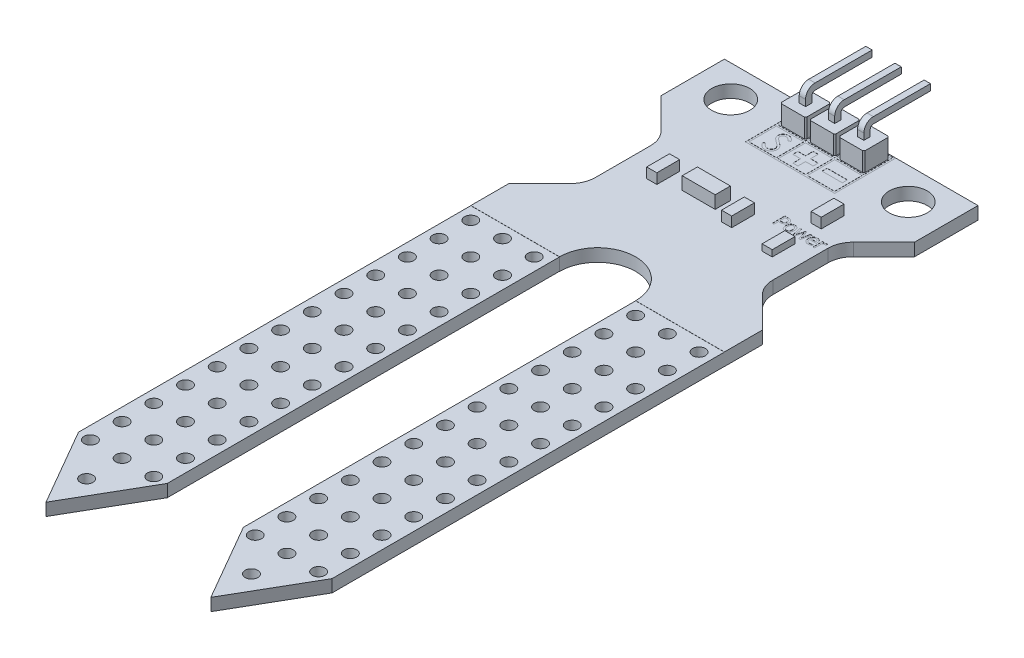
from build123d import *

# Parameters (mm, degrees)
BASE_DEPTH           = 0.5
HOLES_REACH          = 3
SKETCH2_R            = 1.5
PLATE_DEPTH          = 0.49
SKETCH4_R            = 0.5
PLATE_HOLES_DEPTH    = 1.99
SOCKET_DEPTH         = 1.5
POWER_PIN_DEPTH      = 0.25
LPATTERN2_COUNT      = 2
LPATTERN2_PITCH      = 2.3
LPATTERN2_COL_COUNT  = 2
LPATTERN2_COL_PITCH  = 2.3
SKETCH9_W            = 7.04
SKETCH9_H            = 4.74
SKETCH9_W_2          = 2.16
SKETCH9_H_2          = 2.16
SKETCH9_W_3          = 1.6
SKETCH9_H_3          = 0.4
CUT_EXTRUDE3_DEPTH   = 0.01
SKETCH10_W           = 2.6
SKETCH10_H           = 1.2
BIG_RESISTOR_DEPTH   = 1
SKETCH11_W           = 0.8
SKETCH11_H           = 1.8
SMALL_RESISTOR_DEPTH = 0.8
SKETCH12_W           = 0.8
SKETCH12_H           = 1.8
LIGHT_DEPTH          = 0.5


with BuildPart() as part:
    # Sketch1 → Base (new body, symmetric)
    with BuildSketch(Plane(origin=(0, 0, 0), x_dir=(1, 0, 0), z_dir=(0, 1, 0))):
        with BuildLine():
            Line((-10, 0), (10, 0))
            Line((10, 0), (10, -5))
            Line((10, -5), (7.585786438, -7.414213562))
            ThreePointArc((7.585786438, -7.414213562), (7.152240935, -8.06306026), (7, -8.828427125))
            Line((7, -8.828427125), (7, -13.171572875))
            ThreePointArc((7, -13.171572875), (7.152240935, -13.93693974), (7.585786438, -14.585786438))
            Line((7.585786438, -14.585786438), (10, -17))
            Line((10, -17), (10, -20))
            Line((10, -20), (3, -20))
            ThreePointArc((3, -20), (0, -17), (-3, -20))
            Line((-3, -20), (-10, -20))
            Line((-10, -20), (-10, -17))
            Line((-10, -17), (-7.585786438, -14.585786438))
            ThreePointArc((-7.585786438, -14.585786438), (-7.152240935, -13.93693974), (-7, -13.171572875))
            Line((-7, -13.171572875), (-7, -8.828427125))
            ThreePointArc((-7, -8.828427125), (-7.152240935, -8.06306026), (-7.585786438, -7.414213562))
            Line((-7.585786438, -7.414213562), (-10, -5))
            Line((-10, -5), (-10, 0))
        make_face()
    extrude(amount=BASE_DEPTH, both=True)

    # Sketch2 → Holes (cut, up to next)
    with BuildSketch(Plane(origin=(0, 0.5, 0), x_dir=(1, 0, 0), z_dir=(0, 1, 0)), mode=Mode.PRIVATE) as holes_sk1:
        with Locations((-7, -2.5)):
            Circle(SKETCH2_R)
    holes_tool1 = extrude(holes_sk1.sketch, amount=-HOLES_REACH, mode=Mode.PRIVATE) & part.part
    add(holes_tool1.solids().sort_by_distance((-7, 0.5, 2.5))[0], mode=Mode.SUBTRACT)
    # Sketch2 → Holes (cut, up to next)
    with BuildSketch(Plane(origin=(0, 0.5, 0), x_dir=(1, 0, 0), z_dir=(0, 1, 0)), mode=Mode.PRIVATE) as holes_sk2:
        with Locations((7, -2.5)):
            Circle(SKETCH2_R)
    holes_tool2 = extrude(holes_sk2.sketch, amount=-HOLES_REACH, mode=Mode.PRIVATE) & part.part
    add(holes_tool2.solids().sort_by_distance((7, 0.5, 2.5))[0], mode=Mode.SUBTRACT)

    # Sketch3 → Plate (add, symmetric)
    with BuildSketch(Plane(origin=(0, 0, 0), x_dir=(1, 0, 0), z_dir=(0, 1, 0))):
        Polygon((-10, -20), (-3, -20), (-3, -50.937822174), (-6.5, -57), (-10, -50.937822174), align=None)
        Polygon((3, -50.937822174), (3, -20), (10, -20), (10, -50.937822174), (6.5, -57), align=None)
    extrude(amount=PLATE_DEPTH, both=True)

    # Sketch4 → Plate holes (cut, through all)
    with BuildSketch(Plane(origin=(0, 0.49, 0), x_dir=(1, 0, 0), z_dir=(0, 1, 0))):
        with Locations((-9, -21)):
            Circle(SKETCH4_R)
        with Locations((-6.5, -21)):
            Circle(SKETCH4_R)
        with Locations((-4, -21)):
            Circle(SKETCH4_R)
        with Locations((-6.5, -23.5)):
            Circle(SKETCH4_R)
        with Locations((-4, -23.5)):
            Circle(SKETCH4_R)
        with Locations((-6.5, -26)):
            Circle(SKETCH4_R)
        with Locations((-4, -26)):
            Circle(SKETCH4_R)
        with Locations((-6.5, -28.5)):
            Circle(SKETCH4_R)
        with Locations((-4, -28.5)):
            Circle(SKETCH4_R)
        with Locations((-6.5, -31)):
            Circle(SKETCH4_R)
        with Locations((-4, -31)):
            Circle(SKETCH4_R)
        with Locations((-6.5, -33.5)):
            Circle(SKETCH4_R)
        with Locations((-4, -33.5)):
            Circle(SKETCH4_R)
        with Locations((-6.5, -36)):
            Circle(SKETCH4_R)
        with Locations((-4, -36)):
            Circle(SKETCH4_R)
        with Locations((-6.5, -38.5)):
            Circle(SKETCH4_R)
        with Locations((-4, -38.5)):
            Circle(SKETCH4_R)
        with Locations((-6.5, -41)):
            Circle(SKETCH4_R)
        with Locations((-4, -41)):
            Circle(SKETCH4_R)
        with Locations((-6.5, -43.5)):
            Circle(SKETCH4_R)
        with Locations((-4, -43.5)):
            Circle(SKETCH4_R)
        with Locations((-6.5, -46)):
            Circle(SKETCH4_R)
        with Locations((-4, -46)):
            Circle(SKETCH4_R)
        with Locations((-6.5, -48.5)):
            Circle(SKETCH4_R)
        with Locations((-4, -48.5)):
            Circle(SKETCH4_R)
        with Locations((-6.5, -51)):
            Circle(SKETCH4_R)
        with Locations((-4, -51)):
            Circle(SKETCH4_R)
        with Locations((-9, -23.5)):
            Circle(SKETCH4_R)
        with Locations((-9, -26)):
            Circle(SKETCH4_R)
        with Locations((-9, -28.5)):
            Circle(SKETCH4_R)
        with Locations((-9, -31)):
            Circle(SKETCH4_R)
        with Locations((-9, -33.5)):
            Circle(SKETCH4_R)
        with Locations((-9, -36)):
            Circle(SKETCH4_R)
        with Locations((-9, -38.5)):
            Circle(SKETCH4_R)
        with Locations((-9, -41)):
            Circle(SKETCH4_R)
        with Locations((-9, -43.5)):
            Circle(SKETCH4_R)
        with Locations((-9, -46)):
            Circle(SKETCH4_R)
        with Locations((-9, -48.5)):
            Circle(SKETCH4_R)
        with Locations((-9, -51)):
            Circle(SKETCH4_R)
        with Locations((-6.5, -53.8)):
            Circle(SKETCH4_R)
        with Locations((6.5, -53.8)):
            Circle(SKETCH4_R)
        with Locations((9, -51)):
            Circle(SKETCH4_R)
        with Locations((9, -48.5)):
            Circle(SKETCH4_R)
        with Locations((9, -46)):
            Circle(SKETCH4_R)
        with Locations((9, -43.5)):
            Circle(SKETCH4_R)
        with Locations((9, -41)):
            Circle(SKETCH4_R)
        with Locations((9, -38.5)):
            Circle(SKETCH4_R)
        with Locations((9, -36)):
            Circle(SKETCH4_R)
        with Locations((9, -33.5)):
            Circle(SKETCH4_R)
        with Locations((9, -31)):
            Circle(SKETCH4_R)
        with Locations((9, -28.5)):
            Circle(SKETCH4_R)
        with Locations((9, -26)):
            Circle(SKETCH4_R)
        with Locations((9, -23.5)):
            Circle(SKETCH4_R)
        with Locations((4, -51)):
            Circle(SKETCH4_R)
        with Locations((6.5, -51)):
            Circle(SKETCH4_R)
        with Locations((4, -48.5)):
            Circle(SKETCH4_R)
        with Locations((6.5, -48.5)):
            Circle(SKETCH4_R)
        with Locations((4, -46)):
            Circle(SKETCH4_R)
        with Locations((6.5, -46)):
            Circle(SKETCH4_R)
        with Locations((4, -43.5)):
            Circle(SKETCH4_R)
        with Locations((6.5, -43.5)):
            Circle(SKETCH4_R)
        with Locations((4, -41)):
            Circle(SKETCH4_R)
        with Locations((6.5, -41)):
            Circle(SKETCH4_R)
        with Locations((4, -38.5)):
            Circle(SKETCH4_R)
        with Locations((6.5, -38.5)):
            Circle(SKETCH4_R)
        with Locations((4, -36)):
            Circle(SKETCH4_R)
        with Locations((6.5, -36)):
            Circle(SKETCH4_R)
        with Locations((4, -33.5)):
            Circle(SKETCH4_R)
        with Locations((6.5, -33.5)):
            Circle(SKETCH4_R)
        with Locations((4, -31)):
            Circle(SKETCH4_R)
        with Locations((6.5, -31)):
            Circle(SKETCH4_R)
        with Locations((4, -28.5)):
            Circle(SKETCH4_R)
        with Locations((6.5, -28.5)):
            Circle(SKETCH4_R)
        with Locations((4, -26)):
            Circle(SKETCH4_R)
        with Locations((6.5, -26)):
            Circle(SKETCH4_R)
        with Locations((4, -23.5)):
            Circle(SKETCH4_R)
        with Locations((6.5, -23.5)):
            Circle(SKETCH4_R)
        with Locations((4, -21)):
            Circle(SKETCH4_R)
        with Locations((6.5, -21)):
            Circle(SKETCH4_R)
        with Locations((9, -21)):
            Circle(SKETCH4_R)
    extrude(amount=-PLATE_HOLES_DEPTH, mode=Mode.SUBTRACT)

    # Sketch5 → Socket (add)
    with BuildSketch(Plane(origin=(0, 0.5, 0), x_dir=(1, 0, 0), z_dir=(0, 1, 0))):
        Polygon((-3.2, -0.3), (-3.3, -0.4), (-3.3, -2.2), (-3.2, -2.3), (-1.4, -2.3), (-1.3, -2.2), (-1.3, -0.4), (-1.4, -0.3), align=None)
        Polygon((-0.9, -0.3), (-1, -0.4), (-1, -2.2), (-0.9, -2.3), (0.9, -2.3), (1, -2.2), (1, -0.4), (0.9, -0.3), align=None)
        Polygon((1.4, -0.3), (1.3, -0.4), (1.3, -2.2), (1.4, -2.3), (3.2, -2.3), (3.3, -2.2), (3.3, -0.4), (3.2, -0.3), align=None)
    extrude(amount=SOCKET_DEPTH)

    # Sketch7 → Power pin (add, symmetric)
    with BuildSketch(Plane(origin=(0, 0, 0), x_dir=(0, 0, -1), z_dir=(1, 0, 0))):
        with BuildLine():
            Line((-1.05, 2), (-1.05, 2.5))
            ThreePointArc((-1.05, 2.5), (-0.976776695, 2.676776695), (-0.8, 2.75))
            Line((-0.8, 2.75), (3.7, 2.75))
            Line((3.7, 2.75), (3.7, 3.25))
            Line((3.7, 3.25), (-0.8, 3.25))
            ThreePointArc((-0.8, 3.25), (-1.330330086, 3.030330086), (-1.55, 2.5))
            Line((-1.55, 2.5), (-1.55, 2))
            Line((-1.55, 2), (-1.05, 2))
        make_face()
    power_pin = extrude(amount=POWER_PIN_DEPTH, both=True)

    # LPattern2: Power pin ×2
    with Locations(*[(i * LPATTERN2_PITCH, 0, 0) for i in range(1, LPATTERN2_COUNT)]):
        add(power_pin)

    # LPattern2 col: Power pin ×2
    with Locations(*[(-i * LPATTERN2_COL_PITCH, 0, 0) for i in range(1, LPATTERN2_COL_COUNT)]):
        add(power_pin)

    # Sketch9 → Cut-Extrude3 (cut)
    with BuildSketch(Plane(origin=(0, 0.5, 0), x_dir=(1, 0, 0), z_dir=(0, 1, 0))):
        with Locations((0, -2.45)):
            Rectangle(SKETCH9_W, SKETCH9_H)
        with Locations((-2.3, -3.6)):
            Rectangle(SKETCH9_W_2, SKETCH9_H_2, mode=Mode.SUBTRACT)
        with Locations((2.3, -3.6)):
            Rectangle(SKETCH9_W_2, SKETCH9_H_2, mode=Mode.SUBTRACT)
        with Locations((0, -3.6)):
            Rectangle(SKETCH9_W_2, SKETCH9_H_2, mode=Mode.SUBTRACT)
        with Locations((2.3, -1.3)):
            Rectangle(SKETCH9_W_2, SKETCH9_H_2, mode=Mode.SUBTRACT)
        with Locations((0, -1.3)):
            Rectangle(SKETCH9_W_2, SKETCH9_H_2, mode=Mode.SUBTRACT)
        with Locations((-2.3, -1.3)):
            Rectangle(SKETCH9_W_2, SKETCH9_H_2, mode=Mode.SUBTRACT)
        Polygon((0.2, -3.8), (0.2, -4.4), (-0.2, -4.4), (-0.2, -3.8), (-0.8, -3.8), (-0.8, -3.4), (-0.2, -3.4), (-0.2, -2.8), (0.2, -2.8), (0.2, -3.4), (0.8, -3.4), (0.8, -3.8), align=None)
        with Locations((2.3, -3.6)):
            Rectangle(SKETCH9_W_3, SKETCH9_H_3)
        with BuildLine():
            add(Edge.make_bspline(
                [(-2.246490385, -4.576153846), (-2.273532617, -4.576315645), (-2.313654059, -4.573047968), (-2.366227141, -4.564203593), (-2.404086372, -4.553842087), (-2.441134062, -4.54125028), (-2.477209816, -4.525751551), (-2.512330919, -4.507176722), (-2.546694255, -4.485939358), (-2.58021238, -4.461223914), (-2.612571051, -4.432437596), (-2.644831422, -4.400374008), (-2.676043505, -4.364163602), (-2.706829687, -4.324386751), (-2.747659195, -4.264495287), (-2.775757513, -4.216295891), (-2.793846154, -4.182764423)],
                knots=[0, 0, 0, 0, 0.11369606, 0.169177916, 0.224159217, 0.278719878, 0.333794217, 0.389241459, 0.445822073, 0.503704281, 0.564293892, 0.627975416, 0.69503826, 0.765372726, 0.839611443, 1, 1, 1, 1], degree=3))
            Line((-2.793846154, -4.182764423), (-2.641682692, -4.091538462))
            add(Edge.make_bspline(
                [(-2.641682692, -4.091538462), (-2.615333113, -4.137281357), (-2.573720129, -4.20142962), (-2.508305323, -4.274072684), (-2.459465517, -4.316713706), (-2.408925617, -4.350224043), (-2.339499767, -4.381822359), (-2.283518044, -4.391635907), (-2.246490385, -4.391538462)],
                knots=[0, 0, 0, 0, 0.3046461, 0.438546905, 0.562322299, 0.677432543, 0.786897393, 1, 1, 1, 1], degree=3))
            add(Edge.make_bspline(
                [(-2.246490385, -4.391538462), (-2.215186191, -4.391820786), (-2.168541844, -4.386320718), (-2.108627287, -4.368972193), (-2.066142471, -4.350573946), (-2.026493488, -4.32827934), (-1.991723956, -4.301359985), (-1.961667208, -4.271219408), (-1.937075124, -4.237593574), (-1.918227568, -4.20143252), (-1.898856875, -4.152032077), (-1.894321716, -4.112425622), (-1.893846154, -4.086490385)],
                knots=[0, 0, 0, 0, 0.180930311, 0.27008822, 0.360156133, 0.448342532, 0.532665842, 0.613833704, 0.693981527, 0.772715977, 0.849335172, 1, 1, 1, 1], degree=3))
            add(Edge.make_bspline(
                [(-1.893846154, -4.086490385), (-1.893676765, -4.055991813), (-1.905960341, -3.99236022), (-1.938768022, -3.936635259), (-1.958389423, -3.909807692)],
                knots=[0, 0, 0, 0, 0.477158319, 1, 1, 1, 1], degree=3))
            add(Edge.make_bspline(
                [(-1.958389423, -3.909807692), (-1.974979405, -3.887924698), (-2.003044983, -3.854740657), (-2.046593296, -3.812409427), (-2.084590972, -3.776886112), (-2.127862178, -3.740740402), (-2.193103704, -3.687488516), (-2.246255026, -3.649200638), (-2.282908654, -3.622788462)],
                knots=[0, 0, 0, 0, 0.189529918, 0.299197872, 0.418925887, 0.548376285, 0.68813637, 1, 1, 1, 1], degree=3))
            add(Edge.make_bspline(
                [(-2.282908654, -3.622788462), (-2.319332486, -3.597298459), (-2.370311348, -3.559474956), (-2.433967391, -3.510236121), (-2.473696699, -3.478200971), (-2.507834061, -3.449097245), (-2.543316445, -3.417339903), (-2.565438588, -3.393305532), (-2.577860577, -3.377956731)],
                knots=[0, 0, 0, 0, 0.347081672, 0.495567816, 0.628357302, 0.74551967, 0.845830751, 1, 1, 1, 1], degree=3))
            add(Edge.make_bspline(
                [(-2.577860577, -3.377956731), (-2.593776531, -3.357350823), (-2.615964811, -3.325716744), (-2.639676206, -3.280617496), (-2.653448515, -3.246424078), (-2.665023886, -3.21184492), (-2.675502407, -3.164553806), (-2.678598853, -3.128201284), (-2.678461538, -3.103918269)],
                knots=[0, 0, 0, 0, 0.262558979, 0.388264447, 0.512667355, 0.63372227, 0.75539386, 1, 1, 1, 1], degree=3))
            add(Edge.make_bspline(
                [(-2.678461538, -3.103918269), (-2.678553734, -3.066252593), (-2.671447507, -3.010220346), (-2.647478206, -2.939595989), (-2.62266971, -2.890054956), (-2.590643888, -2.84481532), (-2.55359371, -2.803356628), (-2.509461666, -2.768505533), (-2.461039929, -2.738048494), (-2.408041541, -2.714232988), (-2.333433939, -2.689984634), (-2.274246585, -2.68435437), (-2.234951923, -2.683846154)],
                knots=[0, 0, 0, 0, 0.165779888, 0.246280008, 0.327460928, 0.408796954, 0.489715241, 0.571376032, 0.655523321, 0.741019483, 0.826546761, 1, 1, 1, 1], degree=3))
            add(Edge.make_bspline(
                [(-2.234951923, -2.683846154), (-2.192822847, -2.683778289), (-2.129561237, -2.691525523), (-2.049769386, -2.719640703), (-2.001713874, -2.743365307), (-1.964102617, -2.767094216), (-1.935419451, -2.788703433), (-1.906353652, -2.813582569), (-1.876668732, -2.841794847), (-1.846876235, -2.873605751), (-1.805150747, -2.921908707), (-1.774984467, -2.960923517), (-1.755384615, -2.988533654)],
                knots=[0, 0, 0, 0, 0.213251813, 0.318830447, 0.426793531, 0.483645951, 0.543603822, 0.60830765, 0.67712676, 0.750685636, 0.828713418, 1, 1, 1, 1], degree=3))
            Line((-1.755384615, -2.988533654), (-1.901418269, -3.099230769))
            add(Edge.make_bspline(
                [(-1.901418269, -3.099230769), (-1.918152053, -3.077154577), (-1.943547889, -3.046203482), (-1.977300729, -3.007374607), (-2.001237063, -2.983063683), (-2.023554691, -2.961103375), (-2.045214679, -2.942300853), (-2.065906655, -2.92647406), (-2.091989734, -2.909580502), (-2.124758085, -2.892855124), (-2.179943857, -2.873750803), (-2.223743197, -2.868638568), (-2.252980769, -2.868461538)],
                knots=[0, 0, 0, 0, 0.189629101, 0.274184089, 0.352183161, 0.423198873, 0.488550946, 0.548473346, 0.601440164, 0.701198082, 0.799591802, 1, 1, 1, 1], degree=3))
            add(Edge.make_bspline(
                [(-2.252980769, -2.868461538), (-2.288760118, -2.86794829), (-2.341326045, -2.875600288), (-2.404161728, -2.904100386), (-2.443540668, -2.93303211), (-2.476282849, -2.967351191), (-2.508192012, -3.020207311), (-2.51686998, -3.066044557), (-2.516923077, -3.096346154)],
                knots=[0, 0, 0, 0, 0.275902964, 0.402370856, 0.528413645, 0.650356379, 0.765895086, 1, 1, 1, 1], degree=3))
            add(Edge.make_bspline(
                [(-2.516923077, -3.096346154), (-2.517539684, -3.115722128), (-2.513143133, -3.144479643), (-2.503403158, -3.182255061), (-2.491936029, -3.210503374), (-2.476063781, -3.239039588), (-2.446620415, -3.280532441), (-2.418546908, -3.309399632), (-2.398293269, -3.328918269)],
                knots=[0, 0, 0, 0, 0.214745861, 0.32293856, 0.434116163, 0.553412311, 0.686072985, 1, 1, 1, 1], degree=3))
            add(Edge.make_bspline(
                [(-2.398293269, -3.328918269), (-2.389042289, -3.337396199), (-2.372125001, -3.35132235), (-2.345275359, -3.371329108), (-2.31778666, -3.392209601), (-2.284886018, -3.416419074), (-2.230365405, -3.455214082), (-2.187146804, -3.486462007), (-2.156346154, -3.508125)],
                knots=[0, 0, 0, 0, 0.124951974, 0.218093899, 0.333502411, 0.468789179, 0.624937586, 1, 1, 1, 1], degree=3))
            add(Edge.make_bspline(
                [(-2.156346154, -3.508125), (-2.118469517, -3.535564261), (-2.063761069, -3.575795807), (-1.996356754, -3.63167221), (-1.952403412, -3.670950709), (-1.912867071, -3.708765499), (-1.878184215, -3.745569323), (-1.848004854, -3.781099122), (-1.815504812, -3.826650485), (-1.782356478, -3.882596668), (-1.744802823, -3.972233355), (-1.732343451, -4.042695168), (-1.732307692, -4.089014423)],
                knots=[0, 0, 0, 0, 0.187773439, 0.272396139, 0.351320997, 0.424334774, 0.491908784, 0.55423322, 0.611267658, 0.716347845, 0.814540086, 1, 1, 1, 1], degree=3))
            add(Edge.make_bspline(
                [(-1.732307692, -4.089014423), (-1.73180834, -4.121010342), (-1.737031862, -4.168370829), (-1.752300775, -4.229625604), (-1.76926769, -4.273294873), (-1.790011741, -4.315849132), (-1.816324044, -4.356173249), (-1.84682563, -4.395159376), (-1.881814286, -4.431768058), (-1.920100785, -4.46537458), (-1.960566684, -4.495269858), (-2.003278223, -4.520195214), (-2.048003875, -4.540540115), (-2.094753202, -4.556431906), (-2.160627295, -4.572091465), (-2.211953075, -4.576287109), (-2.246490385, -4.576153846)],
                knots=[0, 0, 0, 0, 0.121774528, 0.18091956, 0.240256115, 0.300114444, 0.361145948, 0.423500582, 0.488669361, 0.553954105, 0.617581261, 0.680238427, 0.742187389, 0.804663212, 0.868258989, 1, 1, 1, 1], degree=3))
        make_face()
        with BuildLine():
            add(Edge.make_bspline(
                [(3.614912975, -8.391520479), (3.633163899, -8.404040768), (3.658411823, -8.425948178), (3.685654097, -8.46087403), (3.703330738, -8.48928983), (3.717341928, -8.520703016), (3.730875146, -8.568320938), (3.734174902, -8.606496516), (3.734177215, -8.632620163)],
                knots=[0, 0, 0, 0, 0.236652735, 0.354095324, 0.472428991, 0.593574989, 0.720487505, 1, 1, 1, 1], degree=3))
            add(Edge.make_bspline(
                [(3.734177215, -8.632620163), (3.734440026, -8.65413018), (3.73119797, -8.686086104), (3.721473566, -8.727478688), (3.711089093, -8.757085204), (3.698453563, -8.785275409), (3.678015797, -8.819787273), (3.659487713, -8.843157966), (3.645371835, -8.856908137)],
                knots=[0, 0, 0, 0, 0.260381683, 0.387741643, 0.51462425, 0.640165698, 0.76161061, 1, 1, 1, 1], degree=3))
            add(Edge.make_bspline(
                [(3.645371835, -8.856908137), (3.628222596, -8.874168407), (3.59926142, -8.896823181), (3.556438332, -8.920876751), (3.521585919, -8.935975104), (3.483093971, -8.94749291), (3.423362636, -8.958938368), (3.375658725, -8.96133288), (3.342563291, -8.961338517)],
                knots=[0, 0, 0, 0, 0.221351823, 0.332954221, 0.446758858, 0.566651796, 0.698228055, 1, 1, 1, 1], degree=3))
            Line((3.342563291, -8.961338517), (3.227848101, -8.961338517))
            Line((3.227848101, -8.961338517), (3.227848101, -9.328427125))
            Line((3.227848101, -9.328427125), (3.101265823, -9.328427125))
            Line((3.101265823, -9.328427125), (3.101265823, -8.328427125))
            Line((3.101265823, -8.328427125), (3.353045886, -8.328427125))
            add(Edge.make_bspline(
                [(3.353045886, -8.328427125), (3.380558098, -8.328591969), (3.420312752, -8.329842529), (3.470780842, -8.336395884), (3.504037276, -8.342925648), (3.534802149, -8.351368673), (3.572563912, -8.365779841), (3.598766283, -8.380299011), (3.614912975, -8.391520479)],
                knots=[0, 0, 0, 0, 0.30181566, 0.435226341, 0.557564183, 0.673137959, 0.784559398, 1, 1, 1, 1], degree=3))
        make_face()
        with BuildLine():
            add(Edge.make_bspline(
                [(3.537381329, -8.786892315), (3.547149877, -8.777187217), (3.559916605, -8.76124491), (3.573428862, -8.738111904), (3.581476261, -8.720221024), (3.587667462, -8.701198951), (3.59357476, -8.673078574), (3.594986766, -8.650929826), (3.594936709, -8.63578472)],
                knots=[0, 0, 0, 0, 0.248145665, 0.366464644, 0.482520177, 0.601375968, 0.726646544, 1, 1, 1, 1], degree=3))
            add(Edge.make_bspline(
                [(3.594936709, -8.63578472), (3.594789738, -8.619309561), (3.593083931, -8.595126144), (3.585163427, -8.564773287), (3.577223407, -8.544346049), (3.566984326, -8.525610525), (3.549606752, -8.503120705), (3.533738054, -8.488717261), (3.521558544, -8.481116998)],
                knots=[0, 0, 0, 0, 0.276790802, 0.403639623, 0.524779878, 0.643555797, 0.76031789, 1, 1, 1, 1], degree=3))
            add(Edge.make_bspline(
                [(3.521558544, -8.481116998), (3.51078644, -8.473587721), (3.492737769, -8.464957834), (3.467187336, -8.455966479), (3.446090507, -8.450902768), (3.423168412, -8.446938897), (3.387698148, -8.443119788), (3.35971181, -8.442515837), (3.340189873, -8.442351175)],
                knots=[0, 0, 0, 0, 0.208675435, 0.31773578, 0.431465043, 0.554188898, 0.688523325, 1, 1, 1, 1], degree=3))
            Line((3.340189873, -8.442351175), (3.227848101, -8.442351175))
            Line((3.227848101, -8.442351175), (3.227848101, -8.847414467))
            Line((3.227848101, -8.847414467), (3.320213608, -8.847414467))
            add(Edge.make_bspline(
                [(3.320213608, -8.847414467), (3.345029006, -8.847498782), (3.38040532, -8.846178554), (3.424687105, -8.840438303), (3.452502513, -8.834843592), (3.477307912, -8.826876615), (3.50692572, -8.813034705), (3.5261344, -8.798096919), (3.537381329, -8.786892315)],
                knots=[0, 0, 0, 0, 0.321498886, 0.457598653, 0.578008104, 0.688449725, 0.794251854, 1, 1, 1, 1], degree=3))
        make_face(mode=Mode.SUBTRACT)
        with BuildLine():
            add(Edge.make_bspline(
                [(4.133504747, -8.556275226), (4.157708908, -8.556117091), (4.193387837, -8.559333154), (4.238959054, -8.570162328), (4.270538006, -8.581757766), (4.300148249, -8.596705447), (4.327974594, -8.614764037), (4.353885805, -8.636091391), (4.377594091, -8.660673718), (4.39895468, -8.68818389), (4.417660945, -8.718477693), (4.433484694, -8.751425611), (4.446381381, -8.787075761), (4.45617346, -8.825449966), (4.465823875, -8.881619317), (4.468470297, -8.925460695), (4.46835443, -8.955404973)],
                knots=[0, 0, 0, 0, 0.123251869, 0.181667577, 0.238204524, 0.294238286, 0.350327398, 0.406885296, 0.464849193, 0.523978139, 0.584011388, 0.645910249, 0.709879935, 0.776851044, 0.847428363, 1, 1, 1, 1], degree=3))
            add(Edge.make_bspline(
                [(4.46835443, -8.955404973), (4.468440132, -8.98547689), (4.465885837, -9.029395426), (4.456156814, -9.085623055), (4.446332938, -9.123978398), (4.433584947, -9.159691752), (4.417591758, -9.192561483), (4.399016176, -9.22280112), (4.377592314, -9.250149929), (4.353816579, -9.274513371), (4.328036623, -9.295873499), (4.300130224, -9.313699076), (4.270534065, -9.328478991), (4.238918768, -9.339808627), (4.193400942, -9.350723642), (4.157701972, -9.353881609), (4.133504747, -9.35374358)],
                knots=[0, 0, 0, 0, 0.153333766, 0.223622391, 0.290633759, 0.35495793, 0.416591386, 0.476660723, 0.53556016, 0.593317841, 0.649909737, 0.705850098, 0.76176723, 0.818223218, 0.876674041, 1, 1, 1, 1], degree=3))
            add(Edge.make_bspline(
                [(4.133504747, -9.35374358), (4.10862386, -9.35402896), (4.072151508, -9.35062251), (4.025572771, -9.339483559), (3.99360707, -9.32744457), (3.963517901, -9.312446837), (3.935625885, -9.293900583), (3.909962332, -9.271901924), (3.886410802, -9.246816009), (3.865592431, -9.218691769), (3.847184896, -9.188215707), (3.831823056, -9.155224088), (3.819074417, -9.119897826), (3.809561105, -9.082095914), (3.799675387, -9.027316064), (3.797603451, -8.984525297), (3.797468354, -8.955404973)],
                knots=[0, 0, 0, 0, 0.126623541, 0.185762466, 0.243468747, 0.300244888, 0.356694258, 0.413633082, 0.472086135, 0.531600579, 0.591561601, 0.653162287, 0.716692122, 0.782593358, 0.851505953, 1, 1, 1, 1], degree=3))
            add(Edge.make_bspline(
                [(3.797468354, -8.955404973), (3.797423037, -8.925537598), (3.799842636, -8.881781943), (3.809861679, -8.825769598), (3.819893472, -8.787508369), (3.832675029, -8.751763568), (3.848828926, -8.718837531), (3.86760711, -8.688410781), (3.8892135, -8.660786294), (3.913387593, -8.636357672), (3.939329245, -8.614785477), (3.967271781, -8.596739073), (3.996865327, -8.581633766), (4.028612349, -8.57055445), (4.073859575, -8.559076903), (4.109469928, -8.556252731), (4.133504747, -8.556275226)],
                knots=[0, 0, 0, 0, 0.15215776, 0.222425985, 0.289447046, 0.353383267, 0.415396241, 0.475860313, 0.535164909, 0.593567431, 0.650568342, 0.706628112, 0.762632561, 0.819341043, 0.877480489, 1, 1, 1, 1], degree=3))
        make_face()
        with BuildLine():
            add(Edge.make_bspline(
                [(4.133504747, -9.23981953), (4.149190733, -9.239592793), (4.172332857, -9.237948067), (4.201658983, -9.230484331), (4.221583576, -9.222353296), (4.24030695, -9.212583615), (4.257528568, -9.200267482), (4.27338809, -9.185840242), (4.287657002, -9.169002746), (4.300654109, -9.150158349), (4.311666927, -9.128852398), (4.320947897, -9.105299137), (4.328617659, -9.079625684), (4.334485742, -9.051697301), (4.340475529, -9.010212923), (4.341811617, -8.977716598), (4.341772152, -8.955404973)],
                knots=[0, 0, 0, 0, 0.117813136, 0.172982909, 0.226240362, 0.278888294, 0.331025194, 0.384577959, 0.439284859, 0.496204132, 0.555922045, 0.618729177, 0.685842386, 0.756641583, 0.832586194, 1, 1, 1, 1], degree=3))
            add(Edge.make_bspline(
                [(4.341772152, -8.955404973), (4.341758263, -8.932840299), (4.340571814, -8.899987202), (4.334378981, -8.85809569), (4.328940297, -8.829889641), (4.321109067, -8.804140032), (4.311943836, -8.780594801), (4.300743037, -8.759511707), (4.28816199, -8.740550346), (4.273690216, -8.724070255), (4.258117952, -8.709395788), (4.240737102, -8.697393815), (4.222149336, -8.687302838), (4.201990968, -8.6796109), (4.172549115, -8.672035875), (4.149246557, -8.670428434), (4.133504747, -8.670199277)],
                knots=[0, 0, 0, 0, 0.168865469, 0.245063536, 0.316508225, 0.383414248, 0.446027488, 0.50512473, 0.561591387, 0.615756071, 0.668780413, 0.721159218, 0.773209917, 0.826581425, 0.8820582, 1, 1, 1, 1], degree=3))
            add(Edge.make_bspline(
                [(4.133504747, -8.670199277), (4.117703385, -8.670465531), (4.094321293, -8.671998632), (4.064766199, -8.67964518), (4.044475576, -8.68730774), (4.025707892, -8.697330803), (4.008285078, -8.709457347), (3.992534663, -8.724061473), (3.977855539, -8.740490157), (3.965267334, -8.759511868), (3.954140286, -8.780643417), (3.944584221, -8.804051171), (3.937228009, -8.829963176), (3.931344847, -8.858058504), (3.925327868, -8.900005425), (3.924021989, -8.93283022), (3.924050633, -8.955404973)],
                knots=[0, 0, 0, 0, 0.118168361, 0.173522531, 0.227235226, 0.279604634, 0.331867681, 0.385137134, 0.439505692, 0.495847557, 0.554814193, 0.61747273, 0.684091217, 0.75547806, 0.831507727, 1, 1, 1, 1], degree=3))
            add(Edge.make_bspline(
                [(3.924050633, -8.955404973), (3.924024756, -8.977321988), (3.92535849, -9.00929082), (3.931359828, -9.050246465), (3.937248928, -9.077943532), (3.944613659, -9.103652406), (3.954180601, -9.12704612), (3.965302998, -9.148370474), (3.977918899, -9.167737363), (3.992400539, -9.184744131), (4.008285518, -9.199565445), (4.025750671, -9.211861743), (4.044409584, -9.222339027), (4.064730844, -9.230220615), (4.094349603, -9.237714672), (4.117661397, -9.239769093), (4.133504747, -9.23981953)],
                knots=[0, 0, 0, 0, 0.164254543, 0.239131144, 0.309845932, 0.376264969, 0.439181651, 0.498828367, 0.556224232, 0.611937959, 0.665761022, 0.718524477, 0.771580686, 0.825693026, 0.881275248, 1, 1, 1, 1], degree=3))
        make_face(mode=Mode.SUBTRACT)
        Polygon((5.363132911, -8.581591682), (5.493670886, -8.581591682), (5.30715981, -9.328427125), (5.192642405, -9.328427125), (5.012658228, -8.752675542), (4.834058544, -9.328427125), (4.720134494, -9.328427125), (4.53164557, -8.581591682), (4.662183544, -8.581591682), (4.790545886, -9.159914467), (4.965189873, -8.581591682), (5.06744462, -8.581591682), (5.246637658, -9.159914467), align=None)
        with BuildLine():
            add(Edge.make_bspline(
                [(6.075949367, -9.320317948), (6.05385741, -9.32618504), (6.026458349, -9.333135125), (5.992680663, -9.338399823), (5.967536579, -9.340431998), (5.94766475, -9.341040745), (5.933742089, -9.341085353)],
                knots=[0, 0, 0, 0, 0.475715732, 0.586628104, 0.710510572, 1, 1, 1, 1], degree=3))
            add(Edge.make_bspline(
                [(5.933742089, -9.341085353), (5.905474404, -9.341201841), (5.864108178, -9.338115877), (5.81108863, -9.327862759), (5.774973536, -9.316657943), (5.741180178, -9.302671822), (5.710074836, -9.285145726), (5.681331361, -9.26469597), (5.655322015, -9.241043517), (5.632171656, -9.214445099), (5.611804399, -9.185204616), (5.594784777, -9.153164949), (5.580969269, -9.118507636), (5.570030856, -9.081310308), (5.559586309, -9.026636458), (5.557074731, -8.983829812), (5.556962025, -8.954613834)],
                knots=[0, 0, 0, 0, 0.138010658, 0.202054972, 0.263380769, 0.322416081, 0.380379619, 0.43739781, 0.494395079, 0.551685478, 0.60930803, 0.668092451, 0.728494619, 0.791269632, 0.857209837, 1, 1, 1, 1], degree=3))
            add(Edge.make_bspline(
                [(5.556962025, -8.954613834), (5.557232101, -8.925681656), (5.559448729, -8.883130939), (5.569737975, -8.828631505), (5.580222255, -8.791028121), (5.593645603, -8.755694621), (5.610112635, -8.72267673), (5.629582771, -8.692038907), (5.651940911, -8.663941121), (5.676767708, -8.63871778), (5.703589263, -8.616596947), (5.732279337, -8.597829568), (5.762806346, -8.582551037), (5.795292867, -8.570830279), (5.841732555, -8.559229737), (5.878267994, -8.556507808), (5.902887658, -8.556275226)],
                knots=[0, 0, 0, 0, 0.146258879, 0.214368307, 0.27972423, 0.343167653, 0.40496197, 0.465738786, 0.52616162, 0.585963884, 0.644155795, 0.701412426, 0.758739684, 0.816144242, 0.875498069, 1, 1, 1, 1], degree=3))
            add(Edge.make_bspline(
                [(5.902887658, -8.556275226), (5.924777883, -8.556211752), (5.956941739, -8.558332451), (5.997842371, -8.566989844), (6.025903052, -8.57562061), (6.051943559, -8.587288455), (6.084977422, -8.606002691), (6.106360273, -8.625171823), (6.11965981, -8.638751492)],
                knots=[0, 0, 0, 0, 0.275080864, 0.402883192, 0.52439118, 0.643012812, 0.76060413, 1, 1, 1, 1], degree=3))
            add(Edge.make_bspline(
                [(6.11965981, -8.638751492), (6.133511229, -8.652884347), (6.151018932, -8.677357611), (6.16999828, -8.713287756), (6.181893618, -8.743173351), (6.191228135, -8.776031062), (6.200461371, -8.826216214), (6.202380009, -8.866023237), (6.202531646, -8.893498327)],
                knots=[0, 0, 0, 0, 0.215475753, 0.326952257, 0.443317595, 0.566199288, 0.699558736, 1, 1, 1, 1], degree=3))
            Line((6.202531646, -8.893498327), (6.202531646, -8.961338517))
            Line((6.202531646, -8.961338517), (5.683544304, -8.961338517))
            add(Edge.make_bspline(
                [(5.683544304, -8.961338517), (5.683439481, -8.981703424), (5.685329947, -9.011438152), (5.692383458, -9.049408441), (5.699384009, -9.075231724), (5.708736963, -9.099068361), (5.720047792, -9.121069467), (5.733530411, -9.14111378), (5.749053186, -9.159172715), (5.766297325, -9.175322374), (5.785366748, -9.189148439), (5.805948664, -9.200886607), (5.827953685, -9.210701828), (5.851771036, -9.217937631), (5.88630634, -9.225137647), (5.913346072, -9.227420462), (5.931764241, -9.227161302)],
                knots=[0, 0, 0, 0, 0.147679992, 0.215278435, 0.27976099, 0.341367416, 0.40059095, 0.458794788, 0.516088517, 0.572911673, 0.629706672, 0.686449342, 0.744450636, 0.804022337, 0.866556501, 1, 1, 1, 1], degree=3))
            add(Edge.make_bspline(
                [(5.931764241, -9.227161302), (5.959133356, -9.227017292), (6.01198493, -9.221300892), (6.062284141, -9.204325906), (6.085640823, -9.194329023)],
                knots=[0, 0, 0, 0, 0.518474067, 1, 1, 1, 1], degree=3))
            add(Edge.make_bspline(
                [(6.085640823, -9.194329023), (6.105342705, -9.185627697), (6.13916581, -9.169419984), (6.17003926, -9.148200749), (6.18255538, -9.138553707)],
                knots=[0, 0, 0, 0, 0.577022489, 1, 1, 1, 1], degree=3))
            Line((6.18255538, -9.138553707), (6.189873418, -9.138553707))
            Line((6.189873418, -9.138553707), (6.189873418, -9.278189783))
            add(Edge.make_bspline(
                [(6.189873418, -9.278189783), (6.181619002, -9.281386232), (6.168562873, -9.286522443), (6.150239701, -9.293788263), (6.120886915, -9.305633192), (6.096043586, -9.314862744), (6.075949367, -9.320317948)],
                knots=[0, 0, 0, 0, 0.218524391, 0.346371859, 0.48661077, 1, 1, 1, 1], degree=3))
        make_face()
        with BuildLine():
            add(Edge.make_bspline(
                [(5.74465981, -8.715096429), (5.73547302, -8.724331389), (5.723470228, -8.739553642), (5.709890955, -8.761396236), (5.701881814, -8.778813401), (5.694954945, -8.797132805), (5.688215712, -8.824247913), (5.684405365, -8.845365258), (5.683544304, -8.860072694)],
                knots=[0, 0, 0, 0, 0.242625143, 0.360813104, 0.479167518, 0.599865812, 0.725825642, 1, 1, 1, 1], degree=3))
            Line((5.683544304, -8.860072694), (6.075949367, -8.860072694))
            add(Edge.make_bspline(
                [(6.075949367, -8.860072694), (6.075762026, -8.844572214), (6.073777104, -8.822251916), (6.069002859, -8.793782047), (6.064141677, -8.774925911), (6.05862126, -8.75738918), (6.049018557, -8.736616949), (6.040604765, -8.722078563), (6.033425633, -8.713711935)],
                knots=[0, 0, 0, 0, 0.29959835, 0.432961907, 0.557937652, 0.676115927, 0.788008182, 1, 1, 1, 1], degree=3))
            add(Edge.make_bspline(
                [(6.033425633, -8.713711935), (6.02621831, -8.704616624), (6.0134895, -8.692414538), (5.993726282, -8.679445338), (5.977110388, -8.671575862), (5.958857219, -8.665113532), (5.930663361, -8.658863619), (5.908121839, -8.657802009), (5.892602848, -8.657541049)],
                knots=[0, 0, 0, 0, 0.22124963, 0.334031027, 0.450019854, 0.57145547, 0.703086283, 1, 1, 1, 1], degree=3))
            add(Edge.make_bspline(
                [(5.892602848, -8.657541049), (5.877236141, -8.657544839), (5.854910837, -8.659255698), (5.826652757, -8.665280191), (5.808038221, -8.672006395), (5.790733231, -8.680205782), (5.768888756, -8.693641518), (5.753836624, -8.705881992), (5.74465981, -8.715096429)],
                knots=[0, 0, 0, 0, 0.282218054, 0.410057475, 0.529592748, 0.644999803, 0.7613376, 1, 1, 1, 1], degree=3))
        make_face(mode=Mode.SUBTRACT)
        with BuildLine():
            add(Edge.make_bspline(
                [(6.67147943, -8.581591682), (6.681038773, -8.581480032), (6.697833892, -8.581810029), (6.714412309, -8.584356777), (6.721518987, -8.585349593)],
                knots=[0, 0, 0, 0, 0.571302402, 1, 1, 1, 1], degree=3))
            Line((6.721518987, -8.585349593), (6.721518987, -8.70817396))
            Line((6.721518987, -8.70817396), (6.714992089, -8.70817396))
            add(Edge.make_bspline(
                [(6.714992089, -8.70817396), (6.705234705, -8.70817396), (6.683082806, -8.70817396), (6.660930907, -8.70817396), (6.648536392, -8.70817396)],
                knots=[0, 0, 0, 0, 0.44047619, 1, 1, 1, 1], degree=3))
            add(Edge.make_bspline(
                [(6.648536392, -8.70817396), (6.631779914, -8.708155812), (6.60642886, -8.711075999), (6.573412511, -8.720282086), (6.54862908, -8.730023694), (6.524328415, -8.742500744), (6.49207553, -8.763207448), (6.469693198, -8.782092307), (6.455696203, -8.796188201)],
                knots=[0, 0, 0, 0, 0.230943487, 0.34987543, 0.471981553, 0.597666048, 0.726081612, 1, 1, 1, 1], degree=3))
            Line((6.455696203, -8.796188201), (6.455696203, -9.328427125))
            Line((6.455696203, -9.328427125), (6.329113924, -9.328427125))
            Line((6.329113924, -9.328427125), (6.329113924, -8.581591682))
            Line((6.329113924, -8.581591682), (6.455696203, -8.581591682))
            Line((6.455696203, -8.581591682), (6.455696203, -8.69254896))
            add(Edge.make_bspline(
                [(6.455696203, -8.69254896), (6.476002121, -8.674197728), (6.505844564, -8.649383063), (6.546038829, -8.62162037), (6.572796989, -8.606739842), (6.598161799, -8.595350795), (6.630587027, -8.585181153), (6.655245798, -8.581547094), (6.67147943, -8.581591682)],
                knots=[0, 0, 0, 0, 0.330909707, 0.468650524, 0.589975009, 0.700616191, 0.804234643, 1, 1, 1, 1], degree=3))
        make_face()
    extrude(amount=-CUT_EXTRUDE3_DEPTH, mode=Mode.SUBTRACT)

    # Sketch10 → Big resistor (add)
    with BuildSketch(Plane(origin=(0, 0.5, 0), x_dir=(1, 0, 0), z_dir=(0, 1, 0))):
        with Locations((-1.4, -10.028427125)):
            Rectangle(SKETCH10_W, SKETCH10_H)
    extrude(amount=BIG_RESISTOR_DEPTH)

    # Sketch11 → Small resistor (add)
    with BuildSketch(Plane(origin=(0, 0.5, 0), x_dir=(1, 0, 0), z_dir=(0, 1, 0))):
        with Locations((1.4, -10.328427125)):
            Rectangle(SKETCH11_W, SKETCH11_H)
        with Locations((-4.5, -10.328427125)):
            Rectangle(SKETCH11_W, SKETCH11_H)
        with Locations((5.016317247, -6.881591682)):
            Rectangle(SKETCH11_W, SKETCH11_H)
    extrude(amount=SMALL_RESISTOR_DEPTH)

    # Sketch12 → Light (add)
    with BuildSketch(Plane(origin=(0, 0.5, 0), x_dir=(1, 0, 0), z_dir=(0, 1, 0))):
        with Locations((5, -10.728427125)):
            Rectangle(SKETCH12_W, SKETCH12_H)
    extrude(amount=LIGHT_DEPTH)


solid = part.part
